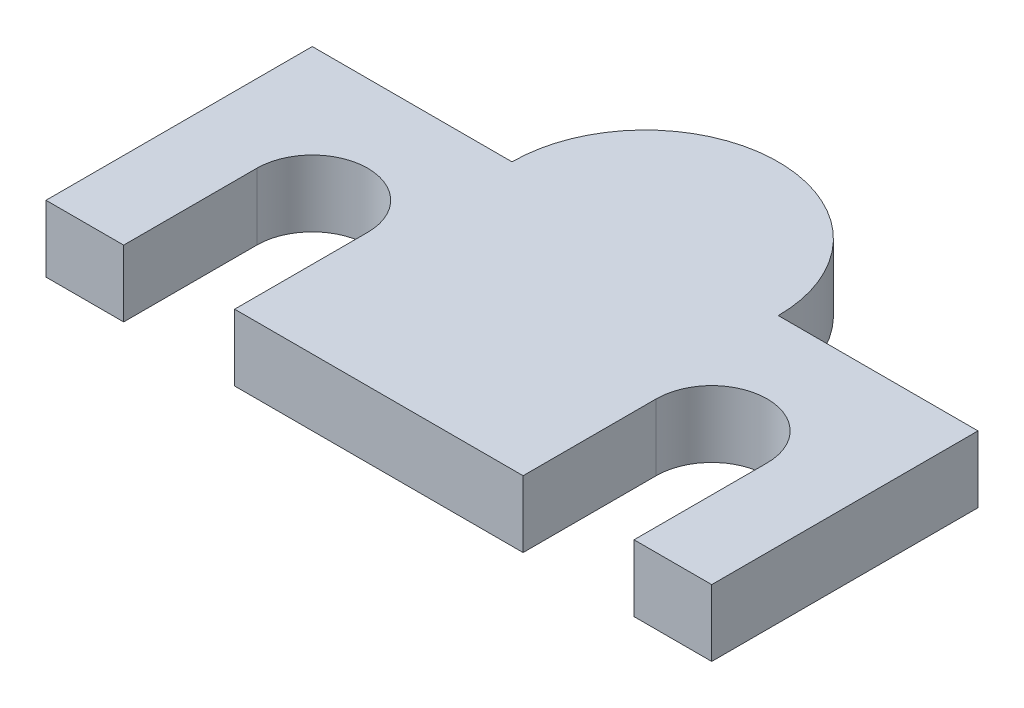
from build123d import *

# Parameters (mm, degrees)
SKETCH1_W           = 30
SKETCH1_H           = 12
BOSS_EXTRUDE1_DEPTH = 3
SKETCH2_R           = 1.5
CUT_EXTRUDE1_DEPTH  = 4
CUT_EXTRUDE2_DEPTH  = 4
BOSS_EXTRUDE2_DEPTH = 3


with BuildPart() as part:
    # Sketch1 → Boss-Extrude1 (new body)
    with BuildSketch(Plane(origin=(0, 0, 0), x_dir=(1, 0, 0), z_dir=(0, 1, 0))):
        Rectangle(SKETCH1_W, SKETCH1_H)
    extrude(amount=BOSS_EXTRUDE1_DEPTH)

    # Sketch2 → Cut-Extrude1 (cut, through all)
    with BuildSketch(Plane(origin=(0, 3, 0), x_dir=(1, 0, 0), z_dir=(0, 1, 0))):
        with Locations((-9, 0)):
            Circle(SKETCH2_R)
        with Locations((9, 0)):
            Circle(SKETCH2_R)
    extrude(amount=-CUT_EXTRUDE1_DEPTH, mode=Mode.SUBTRACT)

    # Sketch3 → Cut-Extrude2 (cut, through all)
    with BuildSketch(Plane(origin=(0, 3, 0), x_dir=(1, 0, 0), z_dir=(0, 1, 0))):
        with BuildLine():
            Line((-6.5, 0), (-6.5, -6))
            ThreePointArc((-6.5, -6), (-9, -8.5), (-11.5, -6))
            Line((-11.5, -6), (-11.5, 0))
            ThreePointArc((-11.5, 0), (-9, 2.5), (-6.5, 0))
        make_face()
        with BuildLine():
            Line((11.5, 0), (11.5, -6))
            ThreePointArc((11.5, -6), (9, -8.5), (6.5, -6))
            Line((6.5, -6), (6.5, 0))
            ThreePointArc((6.5, 0), (9, 2.5), (11.5, 0))
        make_face()
    extrude(amount=-CUT_EXTRUDE2_DEPTH, mode=Mode.SUBTRACT)

    # Sketch4 → Boss-Extrude2 (add)
    with BuildSketch(Plane.XZ):
        with BuildLine():
            Line((-6, -6), (-6, 0))
            ThreePointArc((-6, 0), (0, 6), (6, 0))
            Line((6, 0), (6, -6))
            ThreePointArc((6, -6), (0, -12), (-6, -6))
        make_face()
    extrude(amount=-BOSS_EXTRUDE2_DEPTH)


solid = part.part
